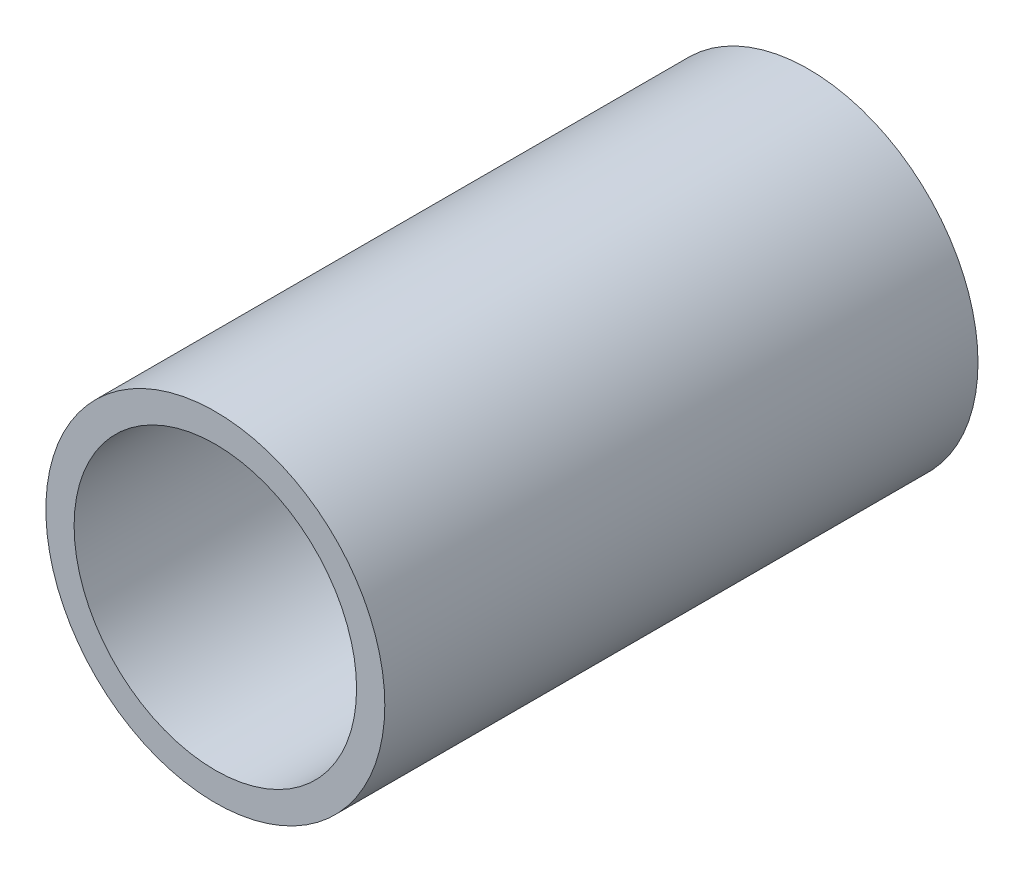
from build123d import *

# Parameters (mm, degrees)
SKETCH1_R           = 12
SKETCH1_R_2         = 10
EXTRUDE_THIN1_DEPTH = 21


with BuildPart() as part:
    # Sketch1 → Extrude-Thin1 (new body, symmetric)
    with BuildSketch(Plane.XY):
        Circle(SKETCH1_R)
        Circle(SKETCH1_R_2, mode=Mode.SUBTRACT)
    extrude(amount=EXTRUDE_THIN1_DEPTH, both=True)


solid = part.part
